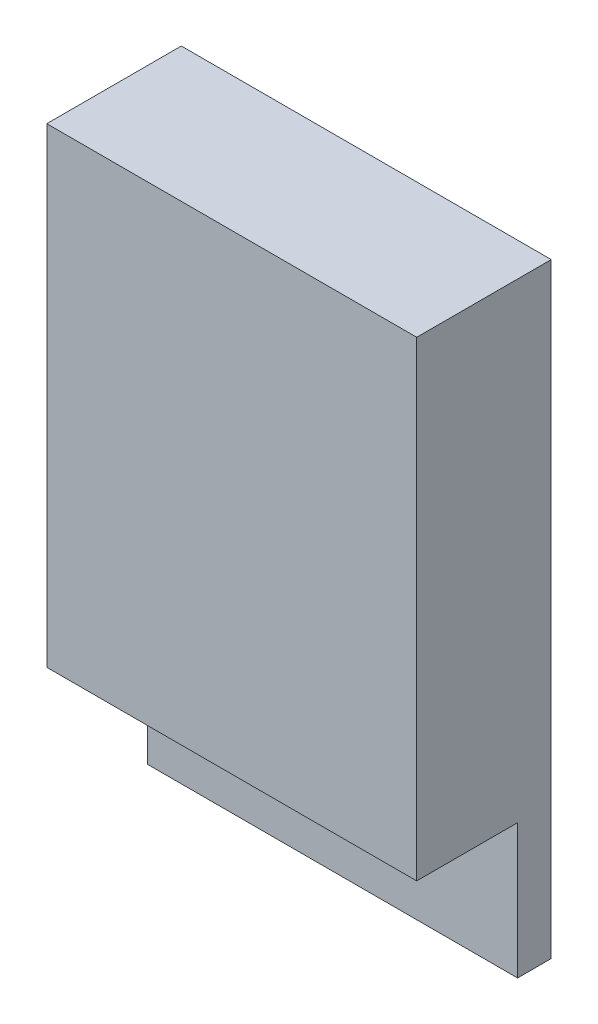
from build123d import *

# Parameters (mm, degrees)
SKETCH1_W           = 27.94
SKETCH1_H           = 45.72
BOSS_EXTRUDE1_DEPTH = 2.54
SKETCH2_W           = 27.94
SKETCH2_H           = 35.56
BOSS_EXTRUDE2_DEPTH = 7.62


with BuildPart() as part:
    # Sketch1 → Boss-Extrude1 (new body)
    with BuildSketch(Plane.XY):
        Rectangle(SKETCH1_W, SKETCH1_H)
    extrude(amount=BOSS_EXTRUDE1_DEPTH)

    # Sketch2 → Boss-Extrude2 (add)
    with BuildSketch(Plane.XY.offset(2.54)):
        with Locations((0, 5.08)):
            Rectangle(SKETCH2_W, SKETCH2_H)
    extrude(amount=BOSS_EXTRUDE2_DEPTH)


solid = part.part
